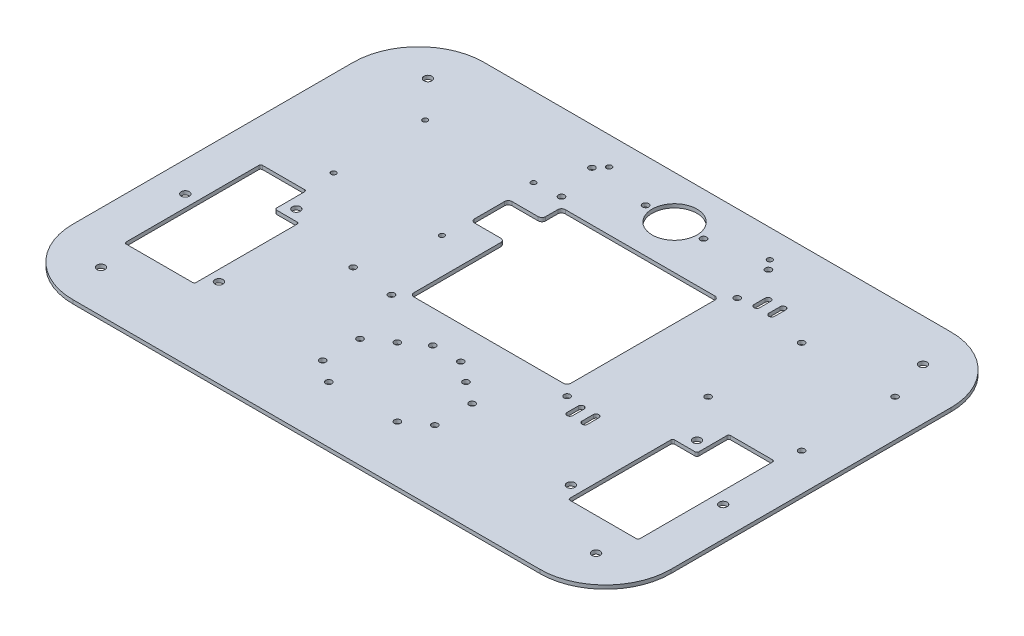
from build123d import *

# Parameters (mm, degrees)
BOSS_EXTRUDE1_DEPTH  = 2
CUT_EXTRUDE8_DEPTH   = 3
SKETCH3_R            = 2.15
CUT_EXTRUDE9_DEPTH   = 3
SKETCH4_R            = 12
SKETCH4_R_2          = 1.65
CUT_EXTRUDE10_DEPTH  = 3
SKETCH8_R            = 2.15
CUT_EXTRUDE11_DEPTH  = 3
FILLET1_R            = 1
FILLET1_OF_MIRROR1_R = 1
SKETCH10_R           = 1.65
SKETCH10_R_2         = 1.35
SKETCH10_W           = 40
SKETCH10_H           = 20
CUT_EXTRUDE13_DEPTH  = 3
SKETCH12_R           = 1.65
SKETCH12_W           = 84
SKETCH12_H           = 81
CUT_EXTRUDE15_DEPTH  = 3
FILLET3_R            = 2
SKETCH11_R           = 1.65
CUT_EXTRUDE14_DEPTH  = 3
SKETCH13_R           = 1.65
SKETCH13_R_2         = 1.4
CUT_EXTRUDE16_DEPTH  = 3
SKETCH14_R           = 1.65
CUT_EXTRUDE17_DEPTH  = 3
CUT_EXTRUDE18_DEPTH  = 3


with BuildPart() as part:
    # Sketch1 → Boss-Extrude1 (new body)
    with BuildSketch(Plane(origin=(0, 0, 0), x_dir=(1, 0, 0), z_dir=(0, 1, 0))):
        with BuildLine():
            Line((125, -110), (-125, -110))
            ThreePointArc((-125, -110), (-149.748737342, -99.748737342), (-160, -75))
            Line((-160, -75), (-160, 75))
            ThreePointArc((-160, 75), (-149.748737342, 99.748737342), (-125, 110))
            Line((-125, 110), (125, 110))
            ThreePointArc((125, 110), (149.748737342, 99.748737342), (160, 75))
            Line((160, 75), (160, -75))
            ThreePointArc((160, -75), (149.748737342, -99.748737342), (125, -110))
        make_face()
    extrude(amount=-BOSS_EXTRUDE1_DEPTH)

    # Sketch2 → Cut-Extrude8 (cut, through all)
    with BuildSketch(Plane(origin=(0, 0, 0), x_dir=(1, 0, 0), z_dir=(0, 1, 0))):
        Polygon((100, -70), (100, -14), (113, -14), (113, 3), (137.5, 3), (137.5, -70), align=None)
    cut_extrude8 = extrude(amount=-CUT_EXTRUDE8_DEPTH, mode=Mode.SUBTRACT)

    # Sketch3 → Cut-Extrude9 (cut, through all)
    with BuildSketch(Plane(origin=(0, 0, 0), x_dir=(1, 0, 0), z_dir=(0, 1, 0))):
        with Locations((94.2, -62.670175326)):
            Circle(SKETCH3_R)
        with Locations((107.2, -8.2)):
            Circle(SKETCH3_R)
        with Locations((143.935832446, -30.9314455)):
            Circle(SKETCH3_R)
    cut_extrude9 = extrude(amount=-CUT_EXTRUDE9_DEPTH, mode=Mode.SUBTRACT)

    # Sketch4 → Cut-Extrude10 (cut, through all)
    with BuildSketch(Plane(origin=(0, 0, 0), x_dir=(1, 0, 0), z_dir=(0, 1, 0))):
        with Locations((0, 87)):
            Circle(SKETCH4_R)
        with Locations((-15.5, 87)):
            Circle(SKETCH4_R_2)
        with Locations((15.5, 87)):
            Circle(SKETCH4_R_2)
    extrude(amount=-CUT_EXTRUDE10_DEPTH, mode=Mode.SUBTRACT)

    # Sketch8 → Cut-Extrude11 (cut, through all)
    with BuildSketch(Plane(origin=(0, 0, 0), x_dir=(1, 0, 0), z_dir=(0, 1, 0))):
        with Locations((-132.5, 87.5)):
            Circle(SKETCH8_R)
        with Locations((132.5, 87.5)):
            Circle(SKETCH8_R)
        with Locations((-132.5, -87.5)):
            Circle(SKETCH8_R)
        with Locations((132.5, -87.5)):
            Circle(SKETCH8_R)
    extrude(amount=-CUT_EXTRUDE11_DEPTH, mode=Mode.SUBTRACT)

    # Fillet1
    fillet1_edges = [part.edges().sort_by_distance(p)[0] for p in [
        (137.5, -1, 70),
        (100, -1, 70),
        (100, -1, 14),
        (113, -1, 14),
        (113, -1, -3),
        (137.5, -1, -3),
    ]]
    fillet(fillet1_edges, radius=FILLET1_R)

    # Mirror1: Cut-Extrude8, Cut-Extrude9 across plane
    add(cut_extrude8.mirror(Plane(origin=(0, 0, 0), x_dir=(0, 0, 1), z_dir=(1, 0, 0))), mode=Mode.SUBTRACT)
    add(cut_extrude9.mirror(Plane(origin=(0, 0, 0), x_dir=(0, 0, 1), z_dir=(1, 0, 0))), mode=Mode.SUBTRACT)

    # Fillet1 of Mirror1
    fillet1_of_mirror1_edges = [part.edges().sort_by_distance(p)[0] for p in [
        (-137.5, -1, 70),
        (-100, -1, 70),
        (-100, -1, 14),
        (-113, -1, 14),
        (-113, -1, -3),
        (-137.5, -1, -3),
    ]]
    fillet(fillet1_of_mirror1_edges, radius=FILLET1_OF_MIRROR1_R)

    # Sketch10 → Cut-Extrude13 (cut, through all)
    with BuildSketch(Plane(origin=(0, 0, 0), x_dir=(1, 0, 0), z_dir=(0, 1, 0))):
        with Locations((18.35, -43)):
            Circle(SKETCH10_R)
        with Locations((-18.35, -43)):
            Circle(SKETCH10_R)
        with Locations((-18.35, -79.7)):
            Circle(SKETCH10_R)
        with Locations((18.35, -79.7)):
            Circle(SKETCH10_R)
        with Locations((-56, 67.5)):
            Circle(SKETCH10_R_2)
        with Locations((-114, 67.5)):
            Circle(SKETCH10_R_2)
        with Locations((-114, 18.5)):
            Circle(SKETCH10_R_2)
        with Locations((-56, 18.5)):
            Circle(SKETCH10_R_2)
        with Locations((-7.5, -34.9314455)):
            Circle(SKETCH10_R)
        with Locations((7.5, -34.9314455)):
            Circle(SKETCH10_R)
        with Locations((-35, 43)):
            Rectangle(SKETCH10_W, SKETCH10_H)
    extrude(amount=-CUT_EXTRUDE13_DEPTH, mode=Mode.SUBTRACT)

    # Sketch12 → Cut-Extrude15 (cut, through all)
    with BuildSketch(Plane(origin=(0, 0, 0), x_dir=(1, 0, 0), z_dir=(0, 1, 0))):
        with Locations((-42, 68.5)):
            Circle(SKETCH12_R)
        with Locations((52, 68.5)):
            Circle(SKETCH12_R)
        with Locations((-42, -22.5)):
            Circle(SKETCH12_R)
        with Locations((52, -22.5)):
            Circle(SKETCH12_R)
        with Locations((5, 23)):
            Rectangle(SKETCH12_W, SKETCH12_H)
    extrude(amount=-CUT_EXTRUDE15_DEPTH, mode=Mode.SUBTRACT)

    # Fillet3
    fillet3_edges = [part.edges().sort_by_distance(p)[0] for p in [
        (-55, -1, -33),
        (-55, -1, -53),
        (-37, -1, -53),
        (-37, -1, -33),
        (-37, -1, 17.5),
        (-37, -1, -63.5),
        (47, -1, -63.5),
        (47, -1, 17.5),
    ]]
    fillet(fillet3_edges, radius=FILLET3_R)

    # Sketch11 → Cut-Extrude14 (cut, through all)
    with BuildSketch(Plane(origin=(0, 0, 0), x_dir=(1, 0, 0), z_dir=(0, 1, 0))):
        with Locations((90, 65)):
            Circle(SKETCH11_R)
        with Locations((140, 65)):
            Circle(SKETCH11_R)
        with Locations((90, 15)):
            Circle(SKETCH11_R)
        with Locations((140, 15)):
            Circle(SKETCH11_R)
        with Locations((-65, -20)):
            Circle(SKETCH11_R)
    extrude(amount=-CUT_EXTRUDE14_DEPTH, mode=Mode.SUBTRACT)

    # Sketch13 → Cut-Extrude16 (cut, through all)
    with BuildSketch(Plane(origin=(0, 0, 0), x_dir=(1, 0, 0), z_dir=(0, 1, 0))):
        with Locations((-47.25, 90)):
            Circle(SKETCH13_R)
        with Locations((47.25, 90)):
            Circle(SKETCH13_R)
        with Locations((-43, 95)):
            Circle(SKETCH13_R_2)
        with Locations((43, 95)):
            Circle(SKETCH13_R_2)
    extrude(amount=-CUT_EXTRUDE16_DEPTH, mode=Mode.SUBTRACT)

    # Sketch14 → Cut-Extrude17 (cut, through all)
    with BuildSketch(Plane(origin=(0, 0, 0), x_dir=(1, 0, 0), z_dir=(0, 1, 0))):
        with Locations((30, -51.35)):
            Circle(SKETCH14_R)
        with Locations((30, -71.35)):
            Circle(SKETCH14_R)
    cut_extrude17 = extrude(amount=-CUT_EXTRUDE17_DEPTH, mode=Mode.SUBTRACT)

    # Mirror2: Cut-Extrude17 across plane
    add(cut_extrude17.mirror(Plane(origin=(0, 0, 0), x_dir=(0, 0, 1), z_dir=(1, 0, 0))), mode=Mode.SUBTRACT)

    # Sketch16 → Cut-Extrude18 (cut, through all)
    with BuildSketch(Plane(origin=(0, 0, 0), x_dir=(1, 0, 0), z_dir=(0, 1, 0))):
        with BuildLine():
            Line((59.5, 70), (59.5, 76))
            ThreePointArc((59.5, 76), (61, 77.5), (62.5, 76))
            Line((62.5, 76), (62.5, 70))
            ThreePointArc((62.5, 70), (61, 68.5), (59.5, 70))
        make_face()
        with BuildLine():
            Line((67.5, 70), (67.5, 76))
            ThreePointArc((67.5, 76), (69, 77.5), (70.5, 76))
            Line((70.5, 76), (70.5, 70))
            ThreePointArc((70.5, 70), (69, 68.5), (67.5, 70))
        make_face()
        with BuildLine():
            Line((59.5, -30), (59.5, -24))
            ThreePointArc((59.5, -24), (61, -22.5), (62.5, -24))
            Line((62.5, -24), (62.5, -30))
            ThreePointArc((62.5, -30), (61, -31.5), (59.5, -30))
        make_face()
        with BuildLine():
            Line((67.5, -30), (67.5, -24))
            ThreePointArc((67.5, -24), (69, -22.5), (70.5, -24))
            Line((70.5, -24), (70.5, -30))
            ThreePointArc((70.5, -30), (69, -31.5), (67.5, -30))
        make_face()
    extrude(amount=-CUT_EXTRUDE18_DEPTH, mode=Mode.SUBTRACT)


solid = part.part
